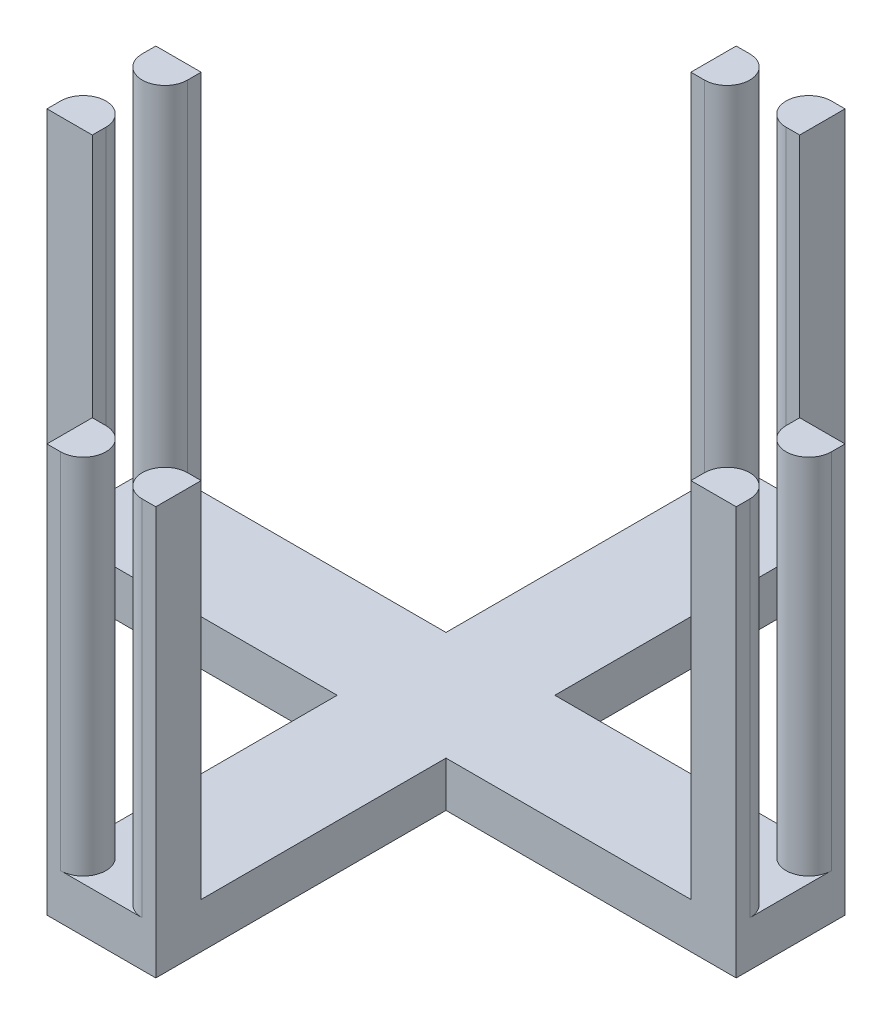
from build123d import *

# Parameters (mm, degrees)
BOSS_EXTRUDE1_DEPTH = 2.5
BOSS_EXTRUDE2_DEPTH = 20
CIRPATTERN1_COUNT   = 4


with BuildPart() as part:
    # Sketch1 → Boss-Extrude1 (new body)
    with BuildSketch(Plane(origin=(0, 0, 0), x_dir=(1, 0, 0), z_dir=(0, 1, 0))):
        Polygon((-3, 3), (-3, 19), (3, 19), (3, 3), (19, 3), (19, -3), (3, -3), (3, -19), (-3, -19), (-3, -3), (-19, -3), (-19, 3), align=None)
    extrude(amount=BOSS_EXTRUDE1_DEPTH)

    # Sketch2 → Boss-Extrude2 (add)
    with BuildSketch(Plane(origin=(0, 2.5, 0), x_dir=(1, 0, 0), z_dir=(0, 1, 0))):
        with BuildLine():
            Line((-2.25, -19), (-3, -19))
            Line((-3, -19), (-3, -16.5))
            Line((-3, -16.5), (-2.25, -16.5))
            ThreePointArc((-2.25, -16.5), (-1, -17.75), (-2.25, -19))
        make_face()
        with BuildLine():
            Line((3, -16.5), (2.25, -16.5))
            ThreePointArc((2.25, -16.5), (1, -17.75), (2.25, -19))
            Line((2.25, -19), (3, -19))
            Line((3, -19), (3, -16.5))
        make_face()
    boss_extrude2 = extrude(amount=BOSS_EXTRUDE2_DEPTH)

    # CirPattern1: Boss-Extrude2 ×4 about axis
    cirpattern1_axis = Axis((0, 0, 0), (0, 1, 0))
    for i in range(1, CIRPATTERN1_COUNT):
        add(boss_extrude2.rotate(cirpattern1_axis, i * 360 / CIRPATTERN1_COUNT))


solid = part.part
